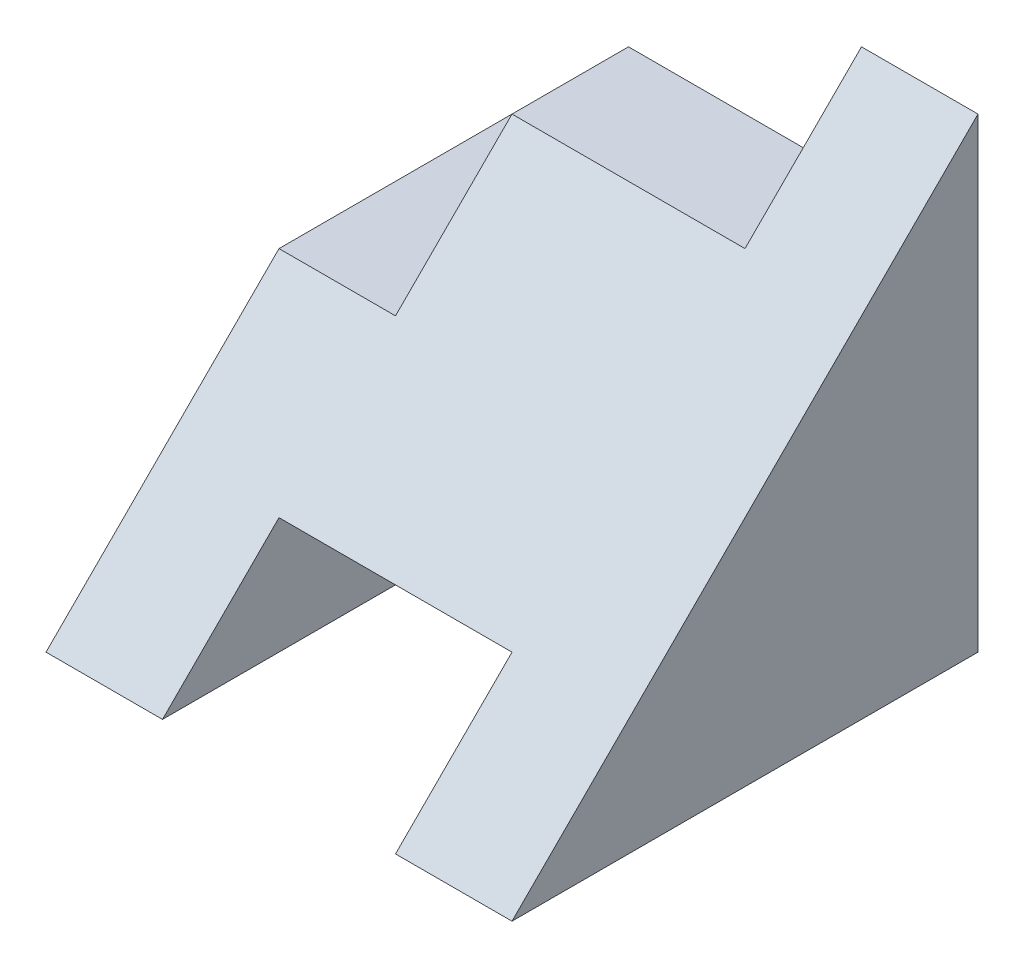
from build123d import *

# Parameters (mm, degrees)
BOSS_EXTRUDE1_DEPTH = 4
CUT_EXTRUDE2_DEPTH  = 10


with BuildPart() as part:
    # Sketch1 → Boss-Extrude1 (new body)
    with BuildSketch(Plane.XY):
        Polygon((0, 0), (0, 2), (1, 2), (1, 3), (3, 3), (3, 4), (4, 4), (4, 0), (3, 0), (3, 1), (1, 1), (1, 0), align=None)
    extrude(amount=BOSS_EXTRUDE1_DEPTH)

    # Sketch3 → Cut-Extrude2 (cut)
    with BuildSketch(Plane.ZY):
        Polygon((4, 0), (0, 4), (4, 4), align=None)
    extrude(amount=-CUT_EXTRUDE2_DEPTH, mode=Mode.SUBTRACT)


solid = part.part
